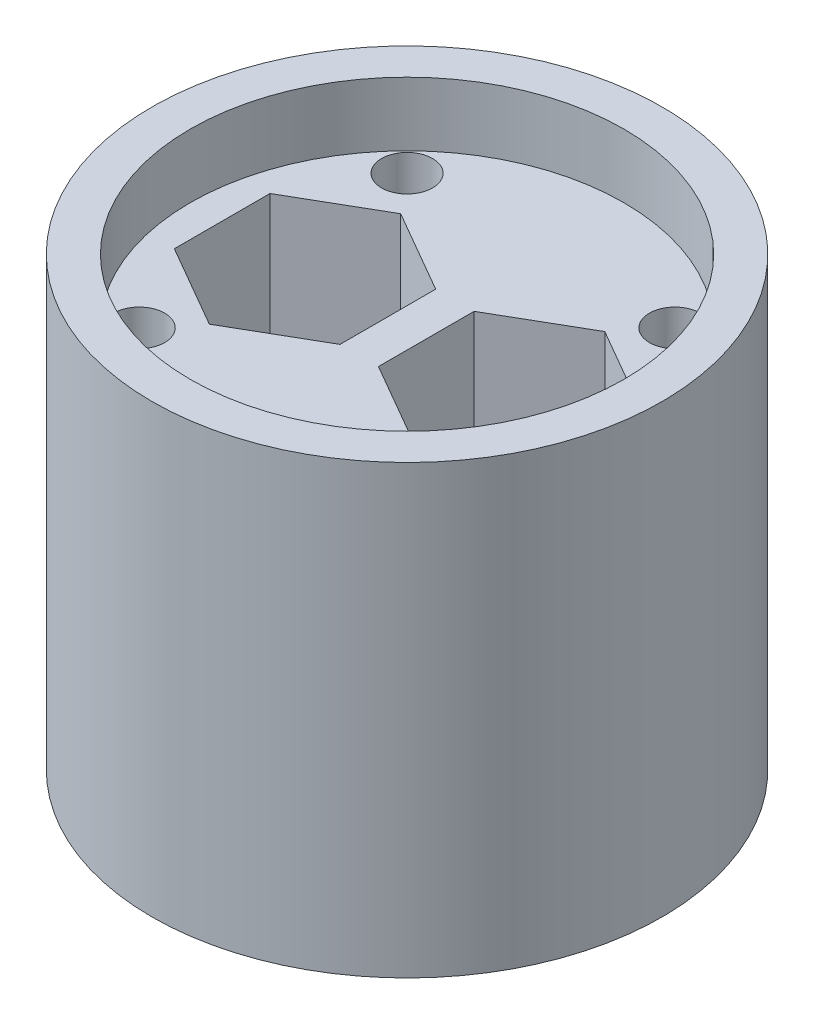
from build123d import *

# Parameters (mm, degrees)
SKETCH1_R           = 20
BOSS_EXTRUDE1_DEPTH = 35
CUT_EXTRUDE1_DEPTH  = 15
SKETCH3_R           = 4.1
CUT_EXTRUDE2_DEPTH  = 21
SKETCH4_R           = 2
CUT_EXTRUDE3_DEPTH  = 36
SKETCH5_R           = 17
CUT_EXTRUDE4_DEPTH  = 5
CUT_EXTRUDE5_DEPTH  = 2


with BuildPart() as part:
    # Sketch1 → Boss-Extrude1 (new body)
    with BuildSketch(Plane(origin=(0, 0, 0), x_dir=(1, 0, 0), z_dir=(0, 1, 0))):
        Circle(SKETCH1_R)
    extrude(amount=BOSS_EXTRUDE1_DEPTH)

    # Sketch2 → Cut-Extrude1 (cut)
    with BuildSketch(Plane(origin=(0, 35, 0), x_dir=(1, 0, 0), z_dir=(0, 1, 0))):
        Polygon((-8, 7.5), (-14.495190528, 3.75), (-14.495190528, -3.75), (-8, -7.5), (-1.504809472, -3.75), (-1.504809472, 3.75), align=None)
        Polygon((8, 7.5), (1.504809472, 3.75), (1.504809472, -3.75), (8, -7.5), (14.495190528, -3.75), (14.495190528, 3.75), align=None)
    extrude(amount=-CUT_EXTRUDE1_DEPTH, mode=Mode.SUBTRACT)

    # Sketch3 → Cut-Extrude2 (cut, through all)
    with BuildSketch(Plane(origin=(0, 20, 0), x_dir=(1, 0, 0), z_dir=(0, 1, 0))):
        with Locations((-8, 0)):
            Circle(SKETCH3_R)
        with Locations((8, 0)):
            Circle(SKETCH3_R)
    extrude(amount=-CUT_EXTRUDE2_DEPTH, mode=Mode.SUBTRACT)

    # Sketch4 → Cut-Extrude3 (cut, through all)
    with BuildSketch(Plane(origin=(0, 35, 0), x_dir=(1, 0, 0), z_dir=(0, 1, 0))):
        with Locations((-10.5, 10.5)):
            Circle(SKETCH4_R)
        with Locations((10.5, 10.5)):
            Circle(SKETCH4_R)
        with Locations((10.5, -10.5)):
            Circle(SKETCH4_R)
        with Locations((-10.5, -10.5)):
            Circle(SKETCH4_R)
    extrude(amount=-CUT_EXTRUDE3_DEPTH, mode=Mode.SUBTRACT)

    # Sketch5 → Cut-Extrude4 (cut)
    with BuildSketch(Plane(origin=(0, 35, 0), x_dir=(1, 0, 0), z_dir=(0, 1, 0))):
        Circle(SKETCH5_R)
    extrude(amount=-CUT_EXTRUDE4_DEPTH, mode=Mode.SUBTRACT)

    # Sketch6 → Cut-Extrude5 (cut)
    with BuildSketch(Plane.XZ):
        with BuildLine():
            Line((8, -8.1), (-8, -8.1))
            ThreePointArc((-8, -8.1), (-16.1, 0), (-8, 8.1))
            Line((-8, 8.1), (8, 8.1))
            ThreePointArc((8, 8.1), (16.1, 0), (8, -8.1))
        make_face()
    extrude(amount=-CUT_EXTRUDE5_DEPTH, mode=Mode.SUBTRACT)


solid = part.part
